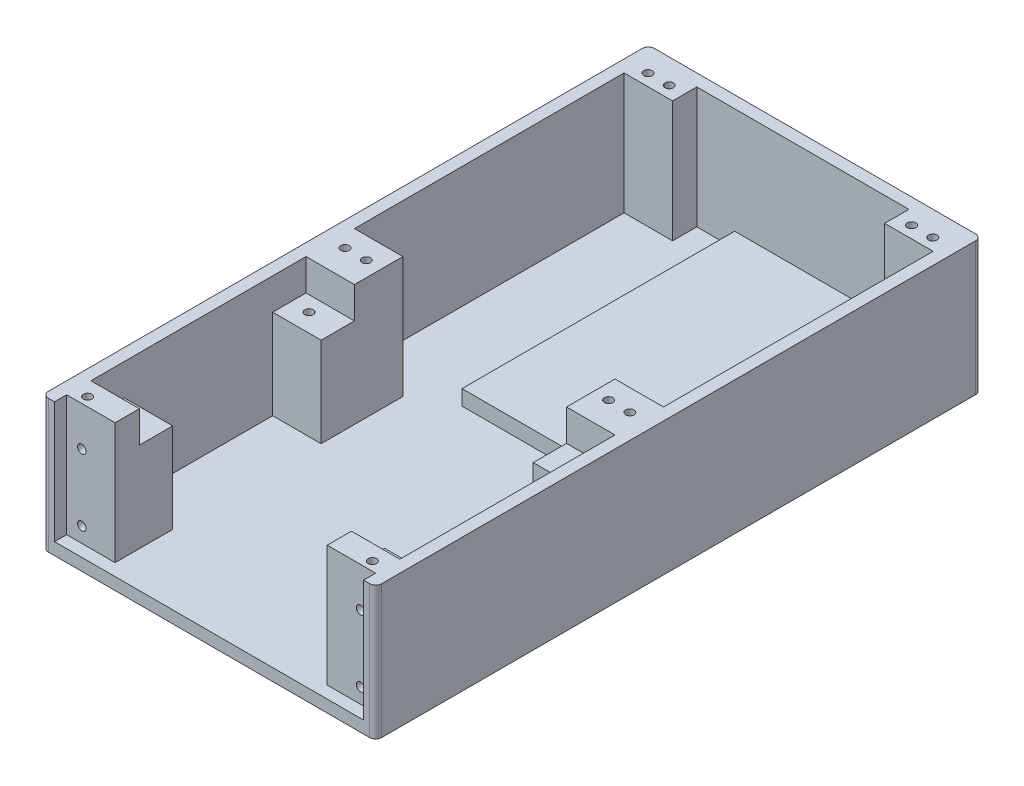
from build123d import *

# Parameters (mm, degrees)
SKETCH1_W                  = 139.7
SKETCH1_H                  = 254
BASE_DEPTH                 = 5.08
SKETCH2_W                  = 139.7
SKETCH2_H                  = 254
SKETCH2_W_2                = 129.54
SKETCH2_H_2                = 243.84
WALLS_DEPTH                = 50.8
SKETCH4_W                  = 129.54
SKETCH4_H                  = 50.8
BOTTOM_CUT_DEPTH           = 139.7
SKETCH12_W                 = 20.32
SKETCH12_H                 = 10.16
SKETCH12_H_2               = 20.32
MOUNTING_STRUTS_DEPTH      = 50.8
SKETCH13_R                 = 1.778
PANEL_MOUNTING_HOLES_DEPTH = 12.7
BOSS_EXTRUDE6_START        = -48.768
SKETCH14_W                 = 20.32
SKETCH14_H                 = 10.16
BOSS_EXTRUDE6_DEPTH        = 50.8
SKETCH17_R                 = 1.778
FRONT_MOUNTING_HOLES_DEPTH = 12.7
CORNER_FILLET_R            = 2.54
SKETCH18_W                 = 20.32
SKETCH18_H                 = 13.97
INSERT_MOUNT_DEPTH         = 37.592
SKETCH19_R                 = 1.778
CUT_EXTRUDE1_DEPTH         = 12.7
SKETCH20_W                 = 57.15
SKETCH20_H                 = 114.3
ARDUINO_MOUNT_DEPTH        = 6.35
SKETCH21_R                 = 1.778
CUT_EXTRUDE2_DEPTH         = 7.62


with BuildPart() as part:
    # Sketch1 → Base (new body)
    with BuildSketch(Plane(origin=(0, 0, 0), x_dir=(1, 0, 0), z_dir=(0, 1, 0))):
        with Locations((69.85, 127)):
            Rectangle(SKETCH1_W, SKETCH1_H)
    extrude(amount=BASE_DEPTH)

    # Sketch2 → Walls (add)
    with BuildSketch(Plane(origin=(0, 5.08, 0), x_dir=(1, 0, 0), z_dir=(0, 1, 0))):
        with Locations((69.85, 127)):
            Rectangle(SKETCH2_W, SKETCH2_H)
        with Locations((69.85, 127)):
            Rectangle(SKETCH2_W_2, SKETCH2_H_2, mode=Mode.SUBTRACT)
    extrude(amount=WALLS_DEPTH)

    # Sketch4 → Bottom Cut (cut)
    with BuildSketch(Plane.XY):
        with Locations((69.85, 30.48)):
            Rectangle(SKETCH4_W, SKETCH4_H)
    extrude(amount=-BOTTOM_CUT_DEPTH, mode=Mode.SUBTRACT)

    # Sketch12 → Mounting Struts (add)
    with BuildSketch(Plane(origin=(0, 5.08, 0), x_dir=(1, 0, 0), z_dir=(0, 1, 0))):
        with Locations((124.46, 243.84)):
            Rectangle(SKETCH12_W, SKETCH12_H)
        with Locations((15.24, 243.84)):
            Rectangle(SKETCH12_W, SKETCH12_H)
        with Locations((124.46, 115.57)):
            Rectangle(SKETCH12_W, SKETCH12_H_2)
        with Locations((15.24, 115.57)):
            Rectangle(SKETCH12_W, SKETCH12_H_2)
    extrude(amount=MOUNTING_STRUTS_DEPTH)

    # Sketch13 → Panel Mounting Holes (cut)
    with BuildSketch(Plane(origin=(0, 55.88, 0), x_dir=(1, 0, 0), z_dir=(0, 1, 0))):
        with Locations((120.65, 243.713)):
            Circle(SKETCH13_R)
        with Locations((19.05, 243.713)):
            Circle(SKETCH13_R)
        with Locations((120.65, 116.713)):
            Circle(SKETCH13_R)
        with Locations((19.05, 116.713)):
            Circle(SKETCH13_R)
    extrude(amount=-PANEL_MOUNTING_HOLES_DEPTH, mode=Mode.SUBTRACT)

    # Sketch14 → Boss-Extrude6 (add)
    with BuildSketch(Plane(origin=(0, 53.848, 0), x_dir=(1, 0, 0), z_dir=(0, 1, 0)).offset(BOSS_EXTRUDE6_START)):
        with Locations((124.46, 10.16)):
            Rectangle(SKETCH14_W, SKETCH14_H)
        with Locations((15.24, 10.16)):
            Rectangle(SKETCH14_W, SKETCH14_H)
    extrude(amount=BOSS_EXTRUDE6_DEPTH)

    # Sketch17 → Front Mounting Holes (cut)
    with BuildSketch(Plane(origin=(0, 55.88, 0), x_dir=(1, 0, 0), z_dir=(0, 1, 0))):
        with Locations((129.54, 243.713)):
            Circle(SKETCH17_R)
        with Locations((10.16, 243.713)):
            Circle(SKETCH17_R)
        with Locations((10.16, 116.713)):
            Circle(SKETCH17_R)
        with Locations((129.54, 116.713)):
            Circle(SKETCH17_R)
        with Locations((129.54, 8.763)):
            Circle(SKETCH17_R)
        with Locations((10.16, 8.763)):
            Circle(SKETCH17_R)
    extrude(amount=-FRONT_MOUNTING_HOLES_DEPTH, mode=Mode.SUBTRACT)

    # Corner Fillet
    corner_fillet_edges = [part.edges().sort_by_distance(p)[0] for p in [
        (0, 27.94, -254),
        (139.7, 27.94, -254),
        (139.7, 27.94, 0),
        (0, 27.94, 0),
    ]]
    fillet(corner_fillet_edges, radius=CORNER_FILLET_R)

    # Sketch18 → Insert Mount (add)
    with BuildSketch(Plane(origin=(0, 5.08, 0), x_dir=(1, 0, 0), z_dir=(0, 1, 0))):
        with Locations((15.24, 98.425)):
            Rectangle(SKETCH18_W, SKETCH18_H)
        with Locations((124.46, 98.425)):
            Rectangle(SKETCH18_W, SKETCH18_H)
        with Locations((124.46, 22.225)):
            Rectangle(SKETCH18_W, SKETCH18_H)
        with Locations((15.24, 22.225)):
            Rectangle(SKETCH18_W, SKETCH18_H)
    extrude(amount=INSERT_MOUNT_DEPTH)

    # Sketch19 → Cut-Extrude1 (cut)
    with BuildSketch(Plane(origin=(0, 42.672, 0), x_dir=(1, 0, 0), z_dir=(0, 1, 0))):
        with Locations((12.7, 99.06)):
            Circle(SKETCH19_R)
        with Locations((127, 99.06)):
            Circle(SKETCH19_R)
        with Locations((127, 21.59)):
            Circle(SKETCH19_R)
        with Locations((12.7, 21.59)):
            Circle(SKETCH19_R)
    extrude(amount=-CUT_EXTRUDE1_DEPTH, mode=Mode.SUBTRACT)

    # Sketch20 → Arduino Mount (add)
    with BuildSketch(Plane(origin=(0, 5.08, 0), x_dir=(1, 0, 0), z_dir=(0, 1, 0))):
        with Locations((69.85, 191.77)):
            Rectangle(SKETCH20_W, SKETCH20_H)
    extrude(amount=ARDUINO_MOUNT_DEPTH)

    # Sketch21 → Cut-Extrude2 (cut)
    with BuildSketch(Plane.XY.offset(-5.08)):
        with Locations((128.27, 11.43)):
            Circle(SKETCH21_R)
        with Locations((128.27, 39.37)):
            Circle(SKETCH21_R)
        with Locations((11.43, 39.37)):
            Circle(SKETCH21_R)
        with Locations((11.43, 11.43)):
            Circle(SKETCH21_R)
    extrude(amount=-CUT_EXTRUDE2_DEPTH, mode=Mode.SUBTRACT)


solid = part.part
